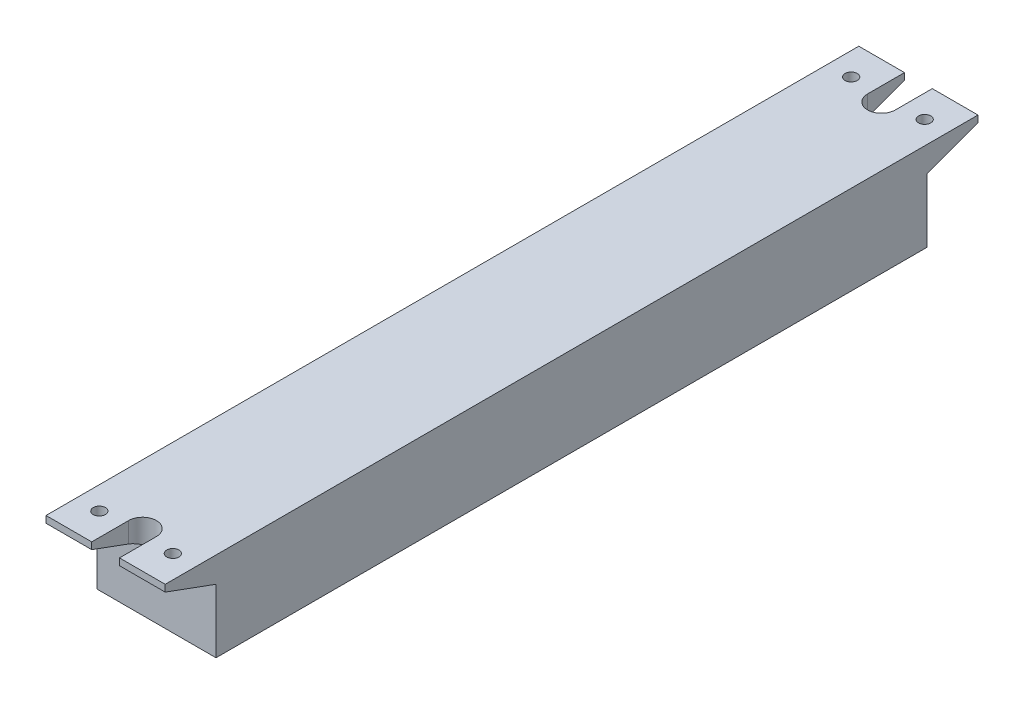
from build123d import *

# Parameters (mm, degrees)
RESSALTO_EXTRUS_O1_DEPTH = 35.2
ESBO_O2_R                = 1.8
CORTE_EXTRUS_O1_DEPTH    = 35.2


with BuildPart() as part:
    # Esboço1 → Ressalto-extrusão1 (new body)
    with BuildSketch(Plane(origin=(0, 0, 0), x_dir=(0, 0, -1), z_dir=(1, 0, 0))):
        Polygon((-105, 13.15), (-120, 13.15), (-120, 11.15), (-105, 5.65), (-105, -13.15), (105, -13.15), (105, 5.65), (120, 11.15), (120, 13.15), (105, 13.15), align=None)
    extrude(amount=RESSALTO_EXTRUS_O1_DEPTH)

    # Esboço2 → Corte-extrusão1 (cut)
    with BuildSketch(Plane.XZ.offset(13.15)):
        with Locations((6.75, 111)):
            Circle(ESBO_O2_R)
        with Locations((28.45, 111)):
            Circle(ESBO_O2_R)
        with Locations((28.45, -111)):
            Circle(ESBO_O2_R)
        with Locations((6.75, -111)):
            Circle(ESBO_O2_R)
        with BuildLine():
            Line((13.5, 109.1), (13.5, 120))
            Line((13.5, 120), (21.7, 120))
            Line((21.7, 120), (21.7, 109.1))
            ThreePointArc((21.7, 109.1), (17.6, 105), (13.5, 109.1))
        make_face()
        with BuildLine():
            Line((13.5, -120), (21.7, -120))
            Line((21.7, -120), (21.7, -109.1))
            ThreePointArc((21.7, -109.1), (17.6, -105), (13.5, -109.1))
            Line((13.5, -109.1), (13.5, -120))
        make_face()
    extrude(amount=-CORTE_EXTRUS_O1_DEPTH, mode=Mode.SUBTRACT)


solid = part.part
